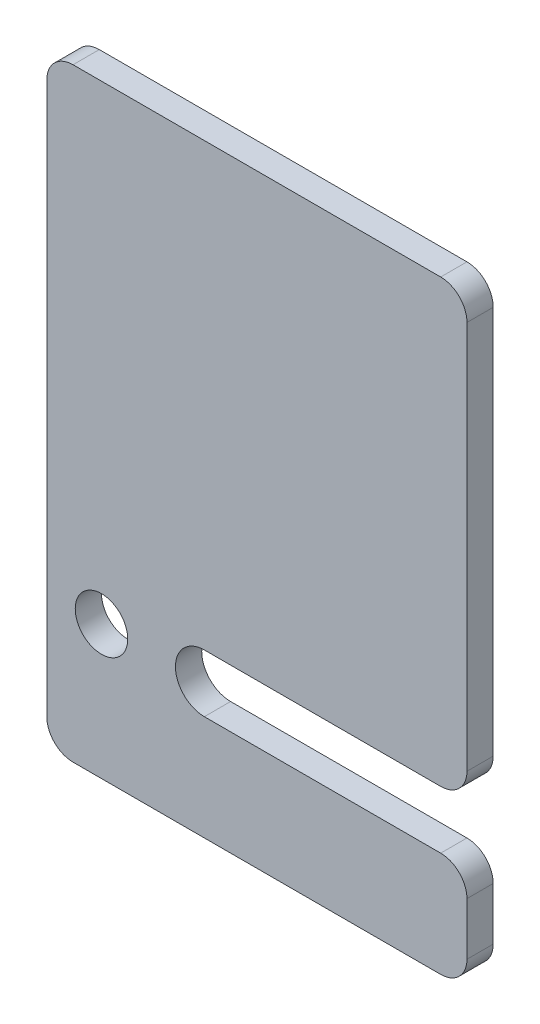
from build123d import *

# Parameters (mm, degrees)
BOSS_EXTRU_1_DEPTH      = 5
ESQUISSE3_R             = 5
ENL_V_MAT_EXTRU_1_DEPTH = 10


with BuildPart() as part:
    # Esquisse1 → Boss.-Extru.1 (new body)
    with BuildSketch(Plane.XY):
        with BuildLine():
            Line((80, 110), (80, 36))
            ThreePointArc((80, 36), (78.535533906, 32.464466094), (75, 31))
            Line((75, 31), (30, 31))
            ThreePointArc((30, 31), (24.5, 25.5), (30, 20))
            Line((30, 20), (75, 20))
            ThreePointArc((75, 20), (78.535533906, 18.535533906), (80, 15))
            Line((80, 15), (80, 5))
            ThreePointArc((80, 5), (78.535533906, 1.464466094), (75, 0))
            Line((75, 0), (5, 0))
            ThreePointArc((5, 0), (1.464466094, 1.464466094), (0, 5))
            Line((0, 5), (0, 110))
            ThreePointArc((0, 110), (1.464466094, 113.535533906), (5, 115))
            Line((5, 115), (75, 115))
            ThreePointArc((75, 115), (78.535533906, 113.535533906), (80, 110))
        make_face()
    extrude(amount=BOSS_EXTRU_1_DEPTH)

    # Esquisse3 → Enlèv. mat.-Extru.1 (cut)
    with BuildSketch(Plane(origin=(0, 0, 0), x_dir=(-1, 0, 0), z_dir=(0, 0, -1))):
        with Locations((-10.415827114, 25.5)):
            Circle(ESQUISSE3_R)
    extrude(amount=-ENL_V_MAT_EXTRU_1_DEPTH, mode=Mode.SUBTRACT)


solid = part.part
